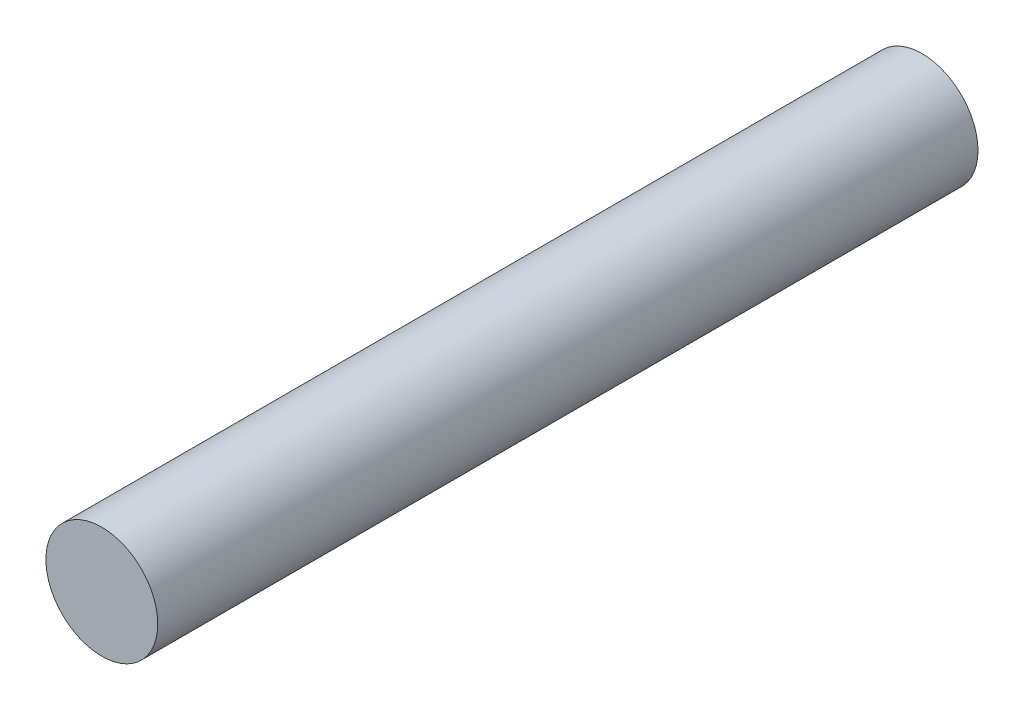
from build123d import *

# Parameters (mm, degrees)
SKETCH_1_R      = 1.5
EXTRUDE_1_DEPTH = 22


with BuildPart() as part:
    # 草图1 → 凸台-拉伸1 (new body)
    with BuildSketch(Plane.XY):
        Circle(SKETCH_1_R)
    extrude(amount=EXTRUDE_1_DEPTH)


solid = part.part
